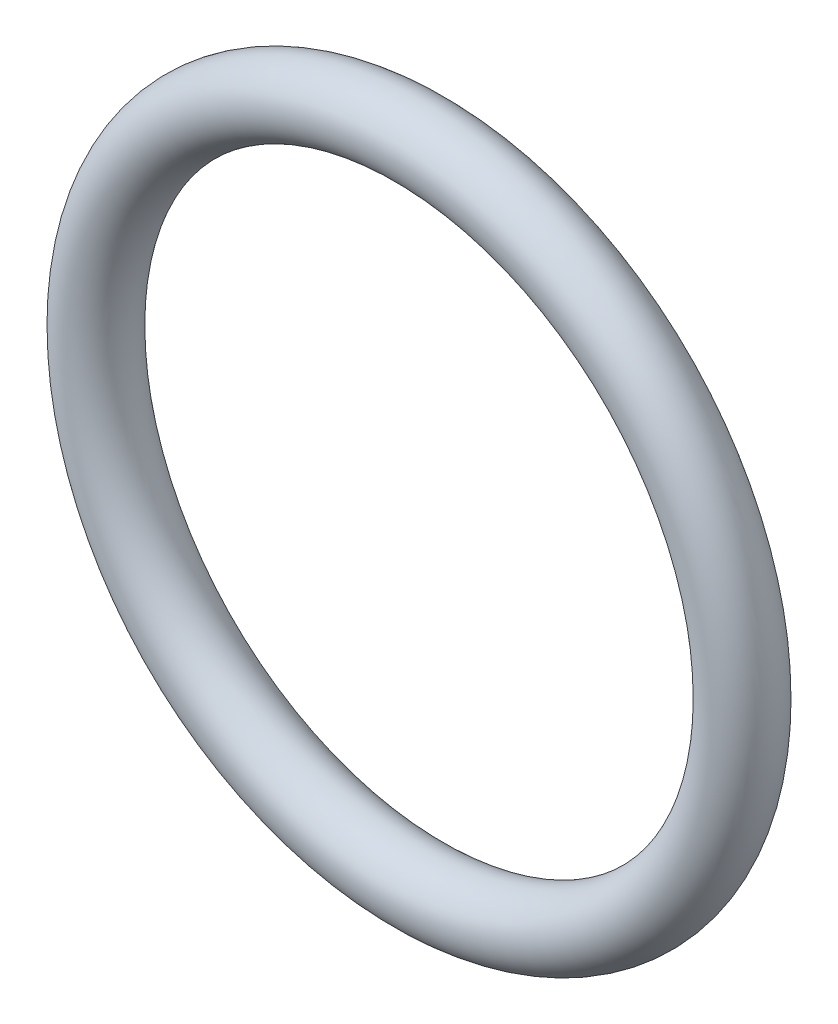
from build123d import *

# Parameters (mm, degrees)
SKETCH1_R = 0.7493


with BuildPart() as part:
    # Sketch1 → Revolve1 (revolve)
    with BuildSketch(Plane(origin=(0, 0, 0), x_dir=(0, 0, -1), z_dir=(1, 0, 0))):
        with Locations((0, 6.9977)):
            Circle(SKETCH1_R)
    revolve(axis=Axis((0, 0, -0.7493), (0, 0, 1)))


solid = part.part
